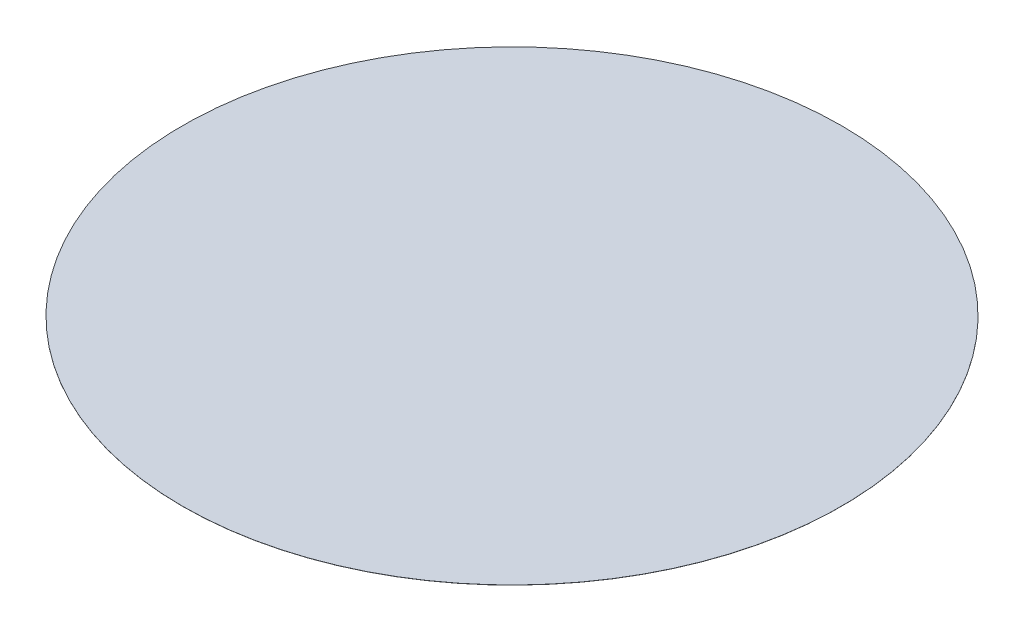
from build123d import *

# Parameters (mm, degrees)
SKETCH1_R           = 27500
BOSS_EXTRUDE1_DEPTH = 5


with BuildPart() as part:
    # Sketch1 → Boss-Extrude1 (new body, symmetric)
    with BuildSketch(Plane(origin=(0, 0, 0), x_dir=(1, 0, 0), z_dir=(0, 1, 0))):
        Circle(SKETCH1_R)
    extrude(amount=BOSS_EXTRUDE1_DEPTH, both=True)


solid = part.part
